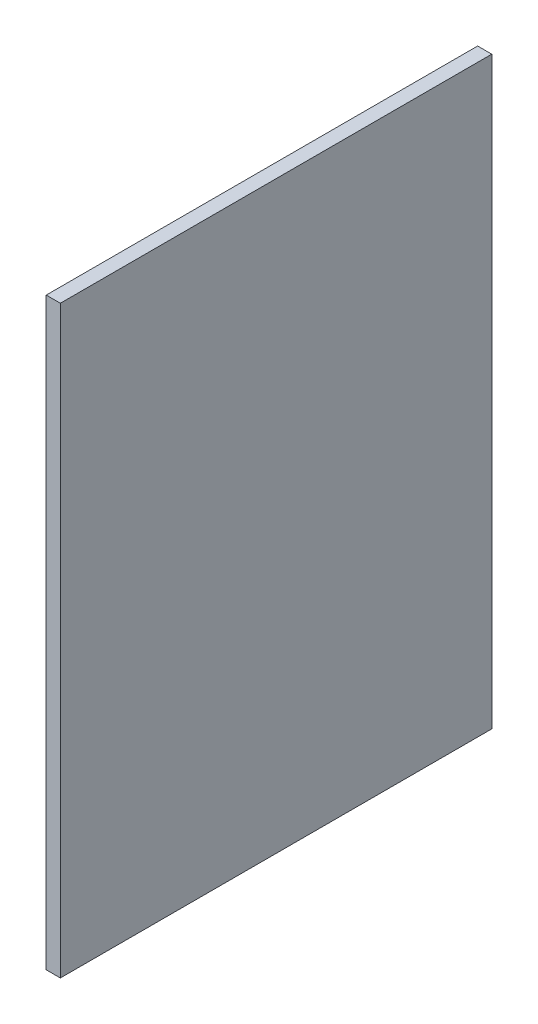
from build123d import *

# Parameters (mm, degrees)
SKETCH1_W           = 550
SKETCH1_H           = 745
BOSS_EXTRUDE1_DEPTH = 18


with BuildPart() as part:
    # Sketch1 → Boss-Extrude1 (new body)
    with BuildSketch(Plane(origin=(0, 0, 0), x_dir=(0, 0, -1), z_dir=(1, 0, 0))):
        with Locations((215.224115979, 298.644528483)):
            Rectangle(SKETCH1_W, SKETCH1_H)
    extrude(amount=BOSS_EXTRUDE1_DEPTH)


solid = part.part
